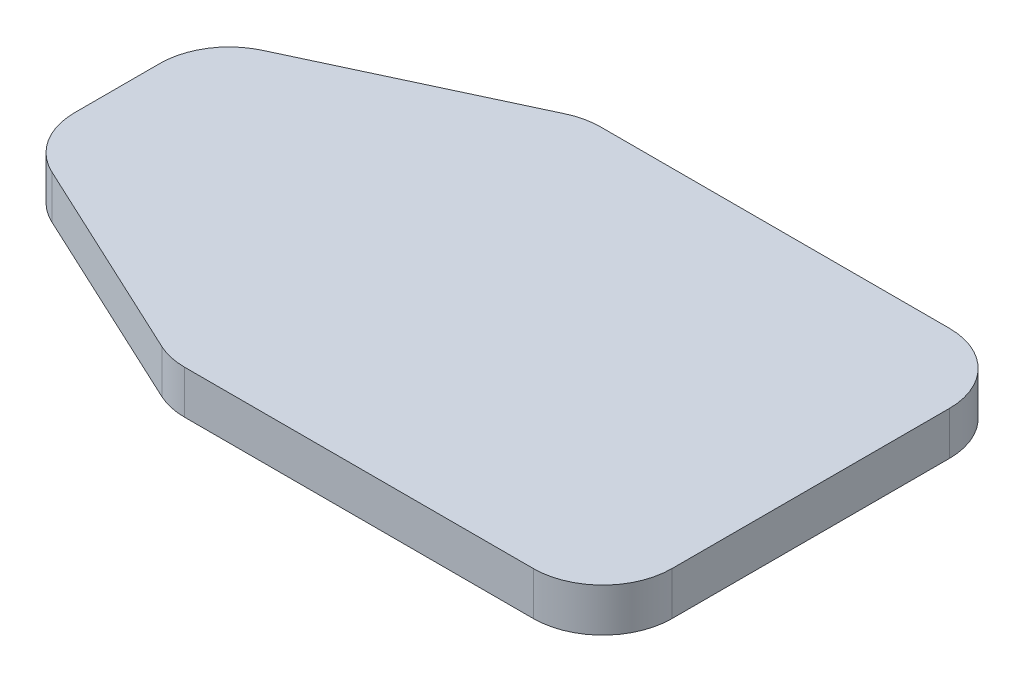
from build123d import *

# Parameters (mm, degrees)
BOSS_EXTRUDE1_DEPTH = 3.175
FILLET2_R           = 5.08


with BuildPart() as part:
    # Sketch1 → Boss-Extrude1 (new body)
    with BuildSketch(Plane(origin=(0, 0, 0), x_dir=(1, 0, 0), z_dir=(0, 1, 0))):
        Polygon((-6.35, 15.24), (-25.4, 6.35), (-25.4, -6.35), (-6.35, -15.24), (25.4, -15.24), (25.4, 15.24), align=None)
    extrude(amount=BOSS_EXTRUDE1_DEPTH)

    # Fillet2
    fillet2_edges = [part.edges().sort_by_distance(p)[0] for p in [
        (-25.4, 1.5875, -6.35),
        (-6.35, 1.5875, -15.24),
        (25.4, 1.5875, -15.24),
        (25.4, 1.5875, 15.24),
        (-6.35, 1.5875, 15.24),
        (-25.4, 1.5875, 6.35),
    ]]
    fillet(fillet2_edges, radius=FILLET2_R)


solid = part.part
